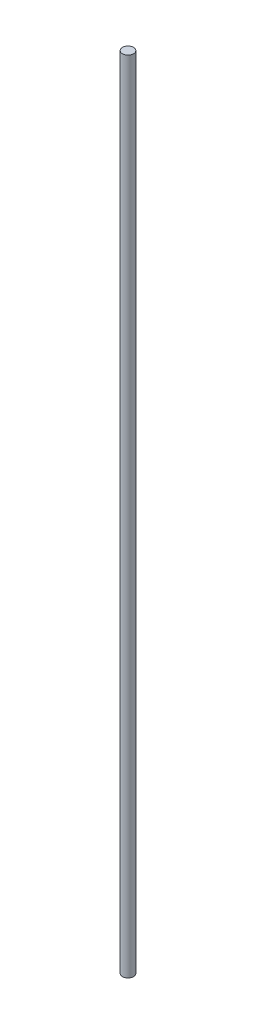
from build123d import *

# Parameters (mm, degrees)
SKETCH1_R           = 1.5875
BOSS_EXTRUDE1_DEPTH = 228.6


with BuildPart() as part:
    # Sketch1 → Boss-Extrude1 (new body)
    with BuildSketch(Plane(origin=(0, 0, 0), x_dir=(1, 0, 0), z_dir=(0, 1, 0))):
        Circle(SKETCH1_R)
    extrude(amount=BOSS_EXTRUDE1_DEPTH)


solid = part.part
